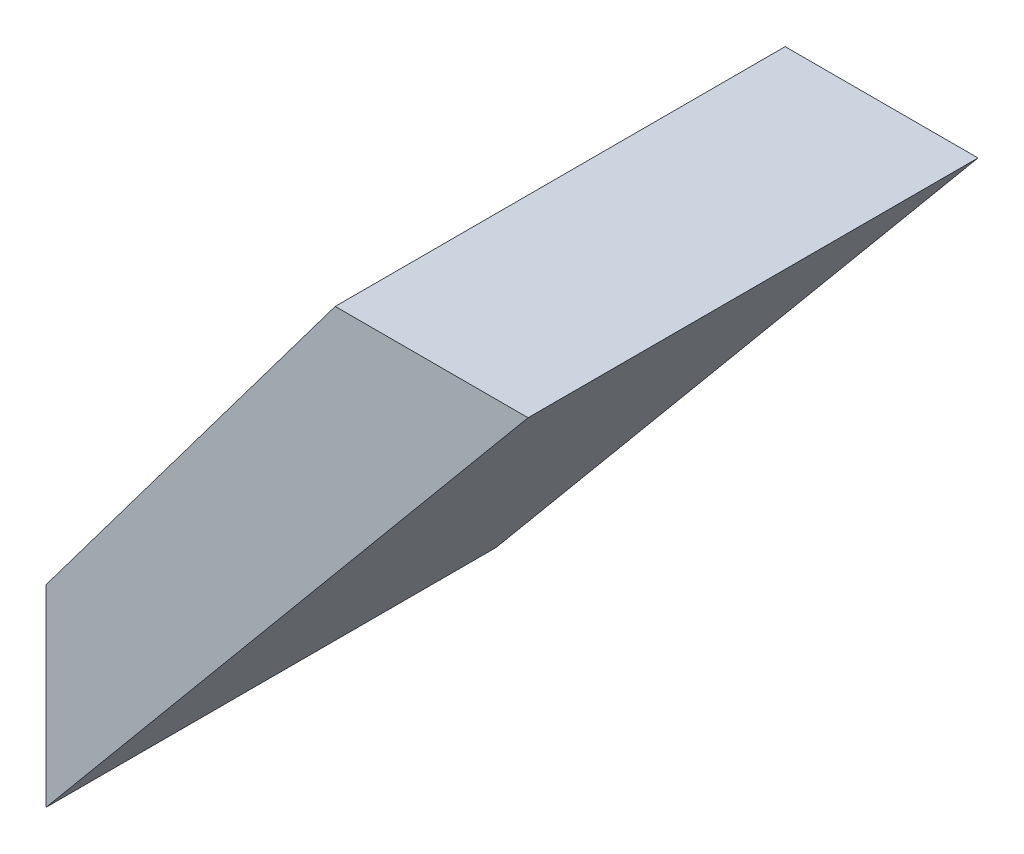
from build123d import *

# Parameters (mm, degrees)
BOSS_EXTRUDE1_DEPTH = 88.9


with BuildPart() as part:
    # Sketch1 → Boss-Extrude1 (new body)
    with BuildSketch(Plane.XY):
        Polygon((82.55, 0), (177.8, 114.3), (139.7, 114.3), (82.55, 38.1), align=None)
    extrude(amount=-BOSS_EXTRUDE1_DEPTH)


solid = part.part
